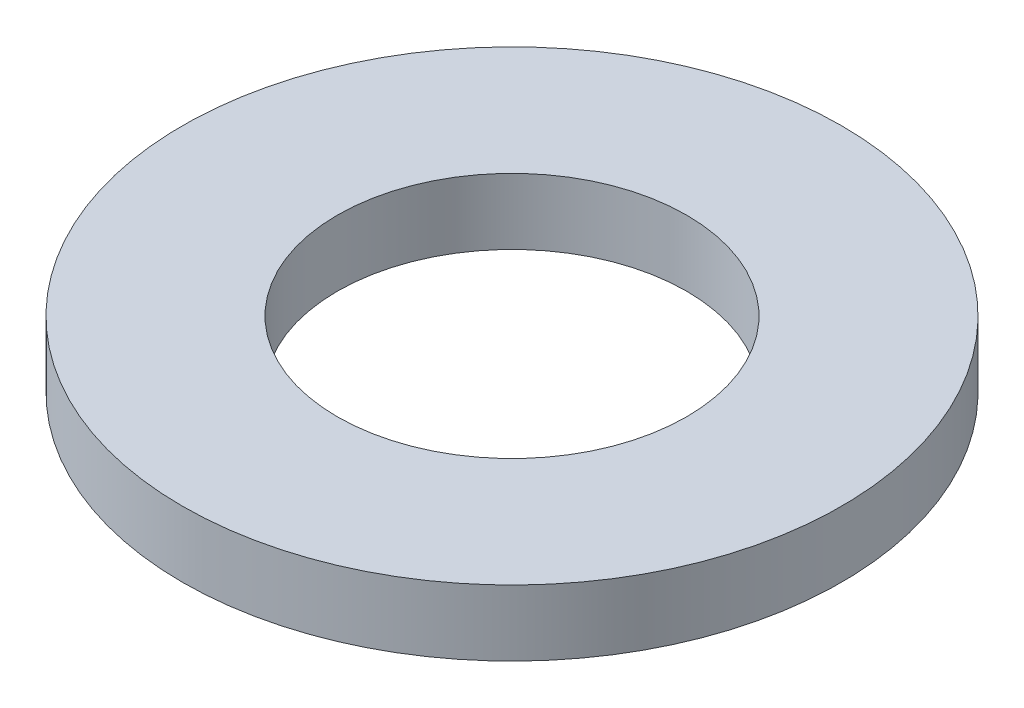
from build123d import *

# Parameters (mm, degrees)
SZKIC1_R                    = 5
SZKIC1_R_2                  = 2.65
DODANIE_WYCI_GNI_CIE1_DEPTH = 1


with BuildPart() as part:
    # Szkic1 → Dodanie-wyciągnięcie1 (new body)
    with BuildSketch(Plane(origin=(0, 0, 0), x_dir=(1, 0, 0), z_dir=(0, 1, 0))):
        Circle(SZKIC1_R)
        Circle(SZKIC1_R_2, mode=Mode.SUBTRACT)
    extrude(amount=DODANIE_WYCI_GNI_CIE1_DEPTH)


solid = part.part
